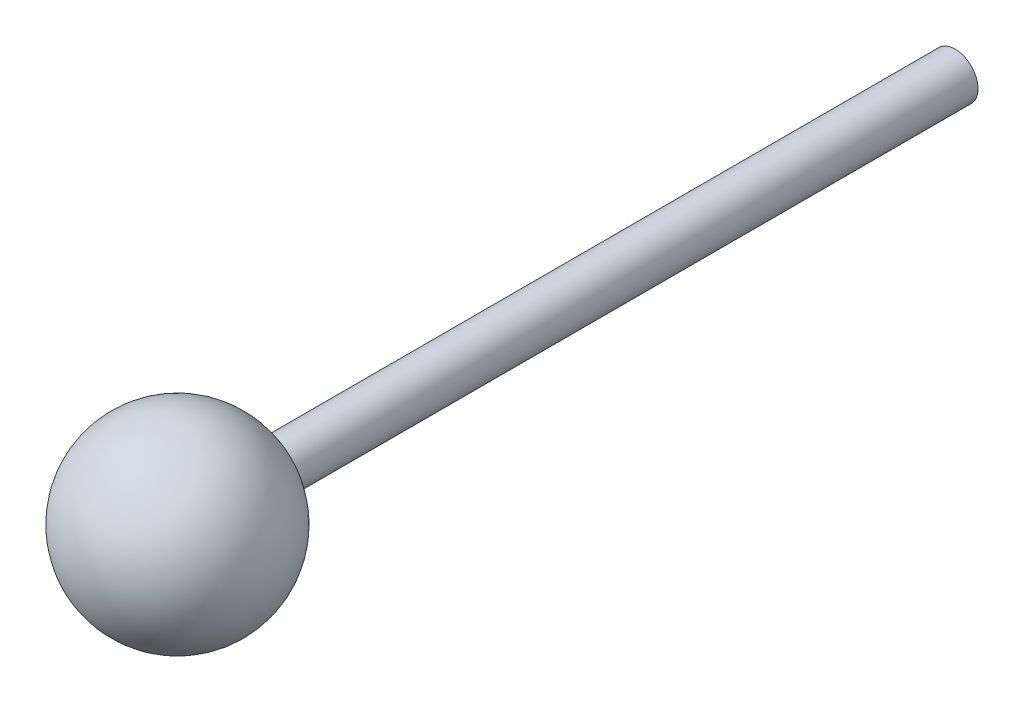
from build123d import *

# Parameters (mm, degrees)
SKETCH1_R           = 0.5
BOSS_EXTRUDE1_DEPTH = 15
DOME1_FACE_RADIUS   = 0.5
DOME1_HEIGHT        = 4


with BuildPart() as part:
    # Sketch1 → Boss-Extrude1 (new body)
    with BuildSketch(Plane.XY):
        with Locations((67.904121243, 47.809178282)):
            Circle(SKETCH1_R)
    extrude(amount=BOSS_EXTRUDE1_DEPTH)

    # Dome1: a dome of height H over a round flat face of radius A is a cap of a sphere of radius (A * A + H * H) / (2 * H)
    dome1_r = (DOME1_FACE_RADIUS * DOME1_FACE_RADIUS + DOME1_HEIGHT * DOME1_HEIGHT) / (2 * DOME1_HEIGHT)
    dome1_base = Plane((67.904121243, 47.809178282, 15), z_dir=(0, 0, 1))
    with Locations(dome1_base.offset(DOME1_HEIGHT - dome1_r)):
        dome1_ball = Sphere(dome1_r, mode=Mode.PRIVATE)
    add(split(dome1_ball, bisect_by=dome1_base, keep=Keep.TOP, mode=Mode.PRIVATE))


solid = part.part
